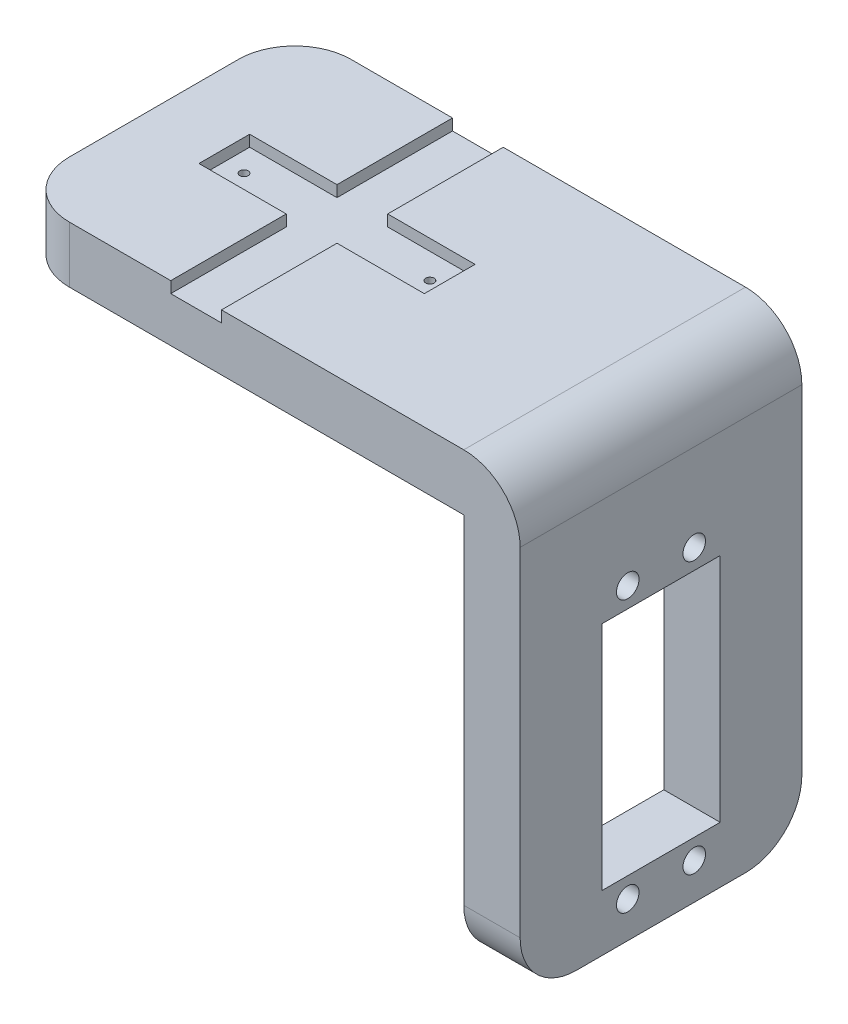
from build123d import *

# Parameters (mm, degrees)
SKETCH1_W                = 60
SKETCH1_H                = 50
BOSS_EXTRUDE1_DEPTH      = 10
SKETCH3_W                = 50
SKETCH3_H                = 10
BOSS_EXTRUDE2_DEPTH      = 20
SKETCH2_W                = 20
SKETCH2_H                = 9
CUT_EXTRUDE2_DEPTH       = 2
SKETCH5_W                = 9
SKETCH5_H                = 20.5
CUT_EXTRUDE3_DEPTH       = 2
SKETCH6_R                = 0.75
CUT_EXTRUDE4_DEPTH       = 9
SKETCH9_W                = 10
SKETCH9_H                = 50
BOSS_EXTRUDE3_DEPTH      = 80
FILLET1_R                = 10
FILLET2_R                = 10
FILLET3_R                = 10
FILLET4_R                = 10
FILLET5_R                = 10
SKETCH11_W               = 10.5
SKETCH11_H               = 41
CUT_EXTRUDE5_DEPTH       = 40
SKETCH13_R               = 2
CUT_EXTRUDE6_DEPTH       = 40
MIRROR11_COPY_1_SKETCH_R = 2
MIRROR11_COPY_1_DEPTH    = 40


with BuildPart() as part:
    # Sketch1 → Boss-Extrude1 (new body)
    with BuildSketch(Plane(origin=(0, 0, 0), x_dir=(1, 0, 0), z_dir=(0, 1, 0))):
        with Locations((8.551590838, -18.42193)):
            Rectangle(SKETCH1_W, SKETCH1_H)
    extrude(amount=BOSS_EXTRUDE1_DEPTH)

    # Sketch3 → Boss-Extrude2 (add)
    with BuildSketch(Plane.ZY.offset(21.448409162)):
        with Locations((18.42193, 5)):
            Rectangle(SKETCH3_W, SKETCH3_H)
    extrude(amount=BOSS_EXTRUDE2_DEPTH)

    # Sketch2 → Cut-Extrude2 (cut)
    with BuildSketch(Plane(origin=(0, 10, 0), x_dir=(1, 0, 0), z_dir=(0, 1, 0))):
        with Locations((-18.948409162, -18.42193)):
            Rectangle(SKETCH2_W, SKETCH2_H)
    cut_extrude2 = extrude(amount=-CUT_EXTRUDE2_DEPTH, mode=Mode.SUBTRACT)

    # Mirror6: Cut-Extrude2 across plane
    add(cut_extrude2.mirror(Plane(origin=(-8.948409162, 8, 22.92193), x_dir=(0, 0, 1), z_dir=(1, 0, 0))), mode=Mode.SUBTRACT)

    # Sketch5 → Cut-Extrude3 (cut)
    with BuildSketch(Plane(origin=(0, 10, 0), x_dir=(1, 0, 0), z_dir=(0, 1, 0))):
        with Locations((-8.948409162, -3.67193)):
            Rectangle(SKETCH5_W, SKETCH5_H)
    cut_extrude3 = extrude(amount=-CUT_EXTRUDE3_DEPTH, mode=Mode.SUBTRACT)

    # Mirror7: Cut-Extrude3 across plane
    add(cut_extrude3.mirror(Plane.XY.offset(18.42193)), mode=Mode.SUBTRACT)

    # Sketch6 → Cut-Extrude4 (cut, through all)
    with BuildSketch(Plane(origin=(0, 8, 0), x_dir=(1, 0, 0), z_dir=(0, 1, 0))):
        with Locations((-25.448409162, -18.42193)):
            Circle(SKETCH6_R)
    cut_extrude4 = extrude(amount=-CUT_EXTRUDE4_DEPTH, mode=Mode.SUBTRACT)

    # Mirror8: Cut-Extrude4 across plane
    add(cut_extrude4.mirror(Plane(origin=(-8.948409162, 0, 0), x_dir=(0, 0, 1), z_dir=(1, 0, 0))), mode=Mode.SUBTRACT)

    # Sketch9 → Boss-Extrude3 (add)
    with BuildSketch(Plane(origin=(0, 10, 0), x_dir=(1, 0, 0), z_dir=(0, 1, 0))):
        with Locations((43.551590838, -18.42193)):
            Rectangle(SKETCH9_W, SKETCH9_H)
    extrude(amount=-BOSS_EXTRUDE3_DEPTH)

    # Fillet1
    fillet1_edges = [part.edges().sort_by_distance(p)[0] for p in [
        (48.551590838, 10, 18.42193),
    ]]
    fillet(fillet1_edges, radius=FILLET1_R)

    # Fillet2
    fillet2_edges = [part.edges().sort_by_distance(p)[0] for p in [
        (-41.448409162, 5, -6.57807),
    ]]
    fillet(fillet2_edges, radius=FILLET2_R)

    # Fillet3
    fillet3_edges = [part.edges().sort_by_distance(p)[0] for p in [
        (-41.448409162, 5, 43.42193),
    ]]
    fillet(fillet3_edges, radius=FILLET3_R)

    # Fillet4
    fillet4_edges = [part.edges().sort_by_distance(p)[0] for p in [
        (43.551590838, -70, 43.42193),
    ]]
    fillet(fillet4_edges, radius=FILLET4_R)

    # Fillet5
    fillet5_edges = [part.edges().sort_by_distance(p)[0] for p in [
        (43.551590838, -70, -6.57807),
    ]]
    fillet(fillet5_edges, radius=FILLET5_R)

    # Sketch11 → Cut-Extrude5 (cut)
    with BuildSketch(Plane.ZY.offset(-38.551590838)):
        with Locations((13.17193, -39.5)):
            Rectangle(SKETCH11_W, SKETCH11_H)
    cut_extrude5 = extrude(amount=-CUT_EXTRUDE5_DEPTH, mode=Mode.SUBTRACT)

    # Mirror9: Cut-Extrude5 across plane
    add(cut_extrude5.mirror(Plane(origin=(78.551590838, -60, 18.42193), x_dir=(1, 0, 0), z_dir=(0, 0, 1))), mode=Mode.SUBTRACT)

    # Sketch13 → Cut-Extrude6 (cut)
    with BuildSketch(Plane.ZY.offset(-38.551590838)):
        with Locations((12.52193, -63.56)):
            Circle(SKETCH13_R)
    cut_extrude6 = extrude(amount=-CUT_EXTRUDE6_DEPTH, mode=Mode.SUBTRACT)

    # Mirror10: Cut-Extrude6 across plane
    add(cut_extrude6.mirror(Plane.XY.offset(18.42193)), mode=Mode.SUBTRACT)

    # Mirror11: Cut-Extrude6 across plane
    add(cut_extrude6.mirror(Plane.ZX.offset(-39.5)), mode=Mode.SUBTRACT)

    # Mirror11 copy 1 sketch → Mirror11 copy 1 (cut)
    with BuildSketch(Plane(origin=(38.551590838, -79, 36.84386), x_dir=(0, 0, -1), z_dir=(-1, 0, 0))):
        with Locations((12.52193, -63.56)):
            Circle(MIRROR11_COPY_1_SKETCH_R)
    extrude(amount=-MIRROR11_COPY_1_DEPTH, mode=Mode.SUBTRACT)


solid = part.part
